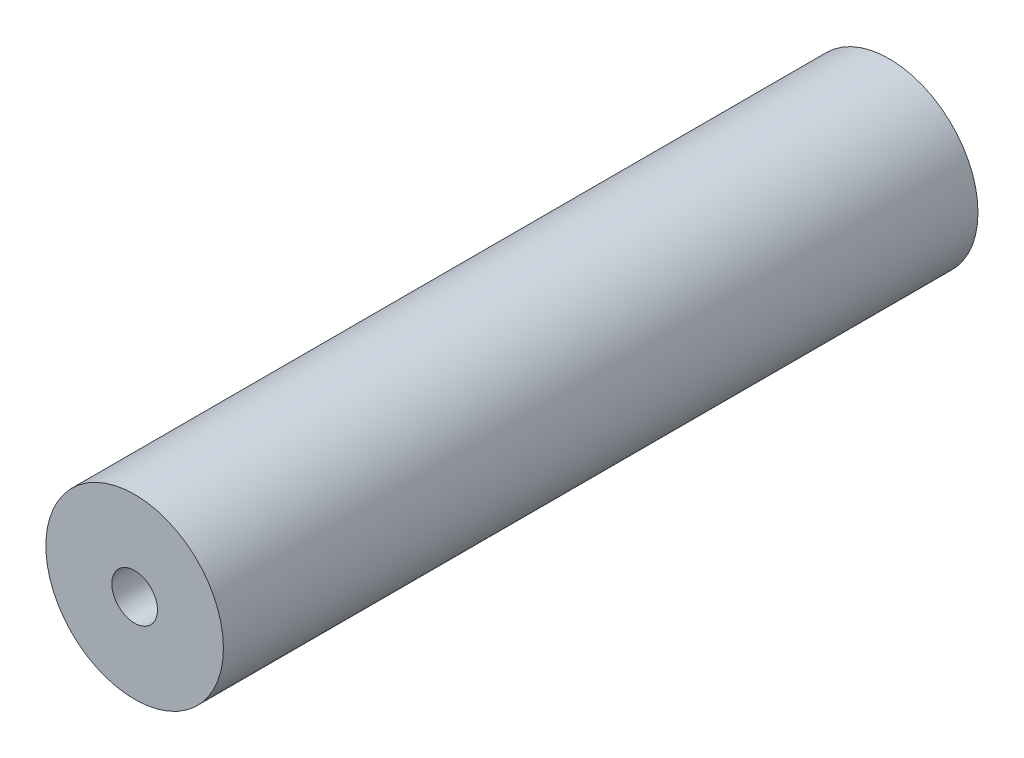
from build123d import *

# Parameters (mm, degrees)
SKETCH1_R                    = 12.7
EXTRUDE1_DEPTH               = 53.975
F_5_16_18_TAPPED_HOLE1_D     = 6.5278
F_5_16_18_TAPPED_HOLE1_DEPTH = 20.32
F_5_16_18_TAPPED_HOLE1_TIP   = 1.961148974


with BuildPart() as part:
    # Sketch1 → Extrude1 (new body, symmetric)
    with BuildSketch(Plane.XY):
        Circle(SKETCH1_R)
    extrude(amount=EXTRUDE1_DEPTH, both=True)

    # 5/16-18 Tapped Hole1
    with Locations(Plane.XY.offset(53.975)):
        with Locations((0, 0)):
            Hole(F_5_16_18_TAPPED_HOLE1_D / 2, depth=F_5_16_18_TAPPED_HOLE1_DEPTH)
            with Locations((0, 0, -(F_5_16_18_TAPPED_HOLE1_DEPTH + F_5_16_18_TAPPED_HOLE1_TIP / 2))):  # 118° drill point
                Cone(0, F_5_16_18_TAPPED_HOLE1_D / 2, F_5_16_18_TAPPED_HOLE1_TIP, mode=Mode.SUBTRACT)


solid = part.part
